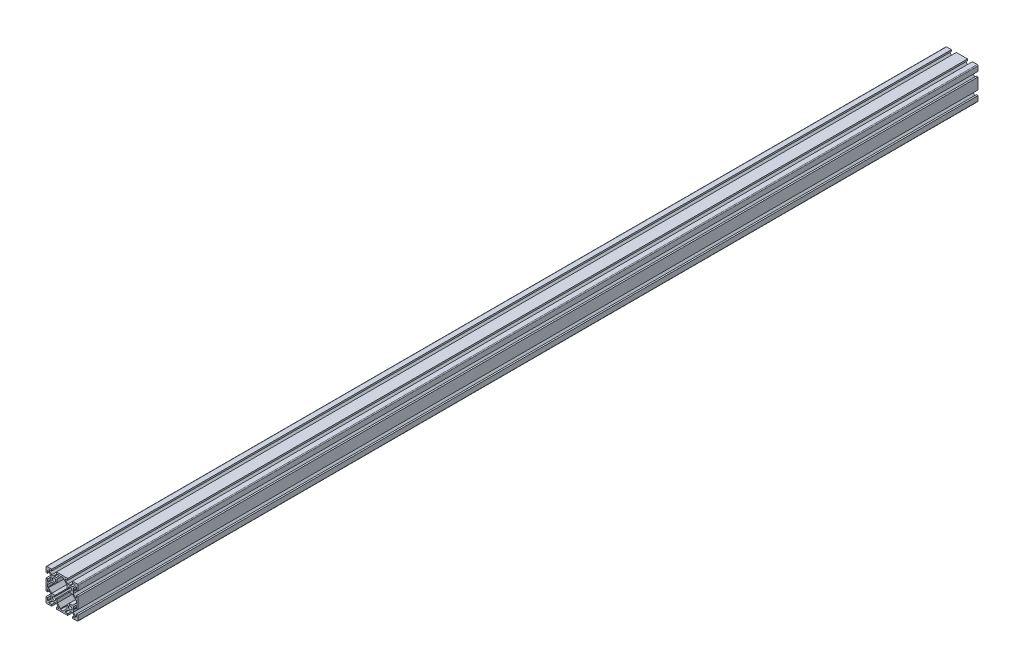
from build123d import *

# Parameters (mm, degrees)
BOSS_EXTRUDE1_DEPTH = 1120
CUT_EXTRUDE1_DEPTH  = 1182


with BuildPart() as part:
    # Sketch1 → Boss-Extrude1 (new body)
    with BuildSketch(Plane.XY):
        with BuildLine():
            Line((-20, 13), (-18, 13))
            Line((-18, 13), (-18, 16))
            Line((-18, 16), (-17.060660172, 16))
            Line((-17.060660172, 16), (-14, 12.939339828))
            Line((-14, 12.939339828), (-14, 10.519615242))
            Line((-14, 10.519615242), (-13.7, 10))
            Line((-13.7, 10), (-14, 9.480384758))
            Line((-14, 9.480384758), (-14, 7.060660172))
            Line((-14, 7.060660172), (-17.060660172, 4))
            Line((-17.060660172, 4), (-18, 4))
            Line((-18, 4), (-18, 7))
            Line((-18, 7), (-20, 7))
            Line((-20, 7), (-20, -7))
            Line((-20, -7), (-18, -7))
            Line((-18, -7), (-18, -4))
            Line((-18, -4), (-17.060660172, -4))
            Line((-17.060660172, -4), (-14, -7.060660172))
            Line((-14, -7.060660172), (-14, -9.480384758))
            Line((-14, -9.480384758), (-13.7, -10))
            Line((-13.7, -10), (-14, -10.519615242))
            Line((-14, -10.519615242), (-14, -12.939339828))
            Line((-14, -12.939339828), (-17.060660172, -16))
            Line((-17.060660172, -16), (-18, -16))
            Line((-18, -16), (-18, -13))
            Line((-18, -13), (-20, -13))
            Line((-20, -13), (-20, -19))
            ThreePointArc((-20, -19), (-19.707106781, -19.707106781), (-19, -20))
            Line((-19, -20), (-13, -20))
            Line((-13, -20), (-13, -18))
            Line((-13, -18), (-16, -18))
            Line((-16, -18), (-16, -17.060660172))
            Line((-16, -17.060660172), (-12.939339828, -14))
            Line((-12.939339828, -14), (-10.519615242, -14))
            Line((-10.519615242, -14), (-10, -13.7))
            Line((-10, -13.7), (-9.480384758, -14))
            Line((-9.480384758, -14), (-7.060660172, -14))
            Line((-7.060660172, -14), (-4, -17.060660172))
            Line((-4, -17.060660172), (-4, -18))
            Line((-4, -18), (-7, -18))
            Line((-7, -18), (-7, -20))
            Line((-7, -20), (7, -20))
            Line((7, -20), (7, -18))
            Line((7, -18), (4, -18))
            Line((4, -18), (4, -17.060660172))
            Line((4, -17.060660172), (7.060660172, -14))
            Line((7.060660172, -14), (9.480384758, -14))
            Line((9.480384758, -14), (10, -13.7))
            Line((10, -13.7), (10.519615242, -14))
            Line((10.519615242, -14), (12.939339828, -14))
            Line((12.939339828, -14), (16, -17.060660172))
            Line((16, -17.060660172), (16, -18))
            Line((16, -18), (13, -18))
            Line((13, -18), (13, -20))
            Line((13, -20), (19, -20))
            ThreePointArc((19, -20), (19.707106781, -19.707106781), (20, -19))
            Line((20, -19), (20, -13))
            Line((20, -13), (18, -13))
            Line((18, -13), (18, -16))
            Line((18, -16), (17.060660172, -16))
            Line((17.060660172, -16), (14, -12.939339828))
            Line((14, -12.939339828), (14, -10.519615242))
            Line((14, -10.519615242), (13.7, -10))
            Line((13.7, -10), (14, -9.480384758))
            Line((14, -9.480384758), (14, -7.060660172))
            Line((14, -7.060660172), (17.060660172, -4))
            Line((17.060660172, -4), (18, -4))
            Line((18, -4), (18, -7))
            Line((18, -7), (20, -7))
            Line((20, -7), (20, 7))
            Line((20, 7), (18, 7))
            Line((18, 7), (18, 4))
            Line((18, 4), (17.060660172, 4))
            Line((17.060660172, 4), (14, 7.060660172))
            Line((14, 7.060660172), (14, 9.480384758))
            Line((14, 9.480384758), (13.7, 10))
            Line((13.7, 10), (14, 10.519615242))
            Line((14, 10.519615242), (14, 12.939339828))
            Line((14, 12.939339828), (17.060660172, 16))
            Line((17.060660172, 16), (18, 16))
            Line((18, 16), (18, 13))
            Line((18, 13), (20, 13))
            Line((20, 13), (20, 19))
            ThreePointArc((20, 19), (19.707106781, 19.707106781), (19, 20))
            Line((19, 20), (13, 20))
            Line((13, 20), (13, 18))
            Line((13, 18), (16, 18))
            Line((16, 18), (16, 17.060660172))
            Line((16, 17.060660172), (12.939339828, 14))
            Line((12.939339828, 14), (10.519615242, 14))
            Line((10.519615242, 14), (10, 13.7))
            Line((10, 13.7), (9.480384758, 14))
            Line((9.480384758, 14), (7.060660172, 14))
            Line((7.060660172, 14), (4, 17.060660172))
            Line((4, 17.060660172), (4, 18))
            Line((4, 18), (7, 18))
            Line((7, 18), (7, 20))
            Line((7, 20), (-7, 20))
            Line((-7, 20), (-7, 18))
            Line((-7, 18), (-4, 18))
            Line((-4, 18), (-4, 17.060660172))
            Line((-4, 17.060660172), (-7.060660172, 14))
            Line((-7.060660172, 14), (-9.480384758, 14))
            Line((-9.480384758, 14), (-10, 13.7))
            Line((-10, 13.7), (-10.519615242, 14))
            Line((-10.519615242, 14), (-12.939339828, 14))
            Line((-12.939339828, 14), (-16, 17.060660172))
            Line((-16, 17.060660172), (-16, 18))
            Line((-16, 18), (-13, 18))
            Line((-13, 18), (-13, 20))
            Line((-13, 20), (-19, 20))
            ThreePointArc((-19, 20), (-19.707106781, 19.707106781), (-20, 19))
            Line((-20, 19), (-20, 13))
        make_face()
    extrude(amount=-BOSS_EXTRUDE1_DEPTH)

    # Sketch2 → Cut-Extrude1 (cut)
    with BuildSketch(Plane.XY):
        with BuildLine():
            Line((-18, 2), (-18, -2))
            Line((-18, -2), (-16.939339828, -2))
            Line((-16.939339828, -2), (-12.939339828, -6))
            Line((-12.939339828, -6), (-8.666662697, -6))
            Line((-8.666662697, -6), (-9.335919912, -8.007765667))
            ThreePointArc((-9.335919912, -8.007765667), (-11.48492424, -11.48492424), (-8.007765667, -9.335919912))
            Line((-8.007765667, -9.335919912), (-6, -8.666662697))
            Line((-6, -8.666662697), (-6, -12.939339828))
            Line((-6, -12.939339828), (-2, -16.939339828))
            Line((-2, -16.939339828), (-2, -18))
            Line((-2, -18), (2, -18))
            Line((2, -18), (2, -16.939339828))
            Line((2, -16.939339828), (6, -12.939339828))
            Line((6, -12.939339828), (6, -8.666662697))
            Line((6, -8.666662697), (8.007765667, -9.335919912))
            ThreePointArc((8.007765667, -9.335919912), (11.48492424, -11.48492424), (9.335919912, -8.007765667))
            Line((9.335919912, -8.007765667), (8.666662697, -6))
            Line((8.666662697, -6), (12.939339828, -6))
            Line((12.939339828, -6), (16.939339828, -2))
            Line((16.939339828, -2), (18, -2))
            Line((18, -2), (18, 2))
            Line((18, 2), (16.939339828, 2))
            Line((16.939339828, 2), (12.939339828, 6))
            Line((12.939339828, 6), (8.666662697, 6))
            Line((8.666662697, 6), (9.335919912, 8.007765667))
            ThreePointArc((9.335919912, 8.007765667), (11.48492424, 11.48492424), (8.007765667, 9.335919912))
            Line((8.007765667, 9.335919912), (6, 8.666662697))
            Line((6, 8.666662697), (6, 12.939339828))
            Line((6, 12.939339828), (2, 16.939339828))
            Line((2, 16.939339828), (2, 18))
            Line((2, 18), (-2, 18))
            Line((-2, 18), (-2, 16.939339828))
            Line((-2, 16.939339828), (-6, 12.939339828))
            Line((-6, 12.939339828), (-6, 8.666662697))
            Line((-6, 8.666662697), (-8.007765667, 9.335919912))
            ThreePointArc((-8.007765667, 9.335919912), (-11.48492424, 11.48492424), (-9.335919912, 8.007765667))
            Line((-9.335919912, 8.007765667), (-8.666662697, 6))
            Line((-8.666662697, 6), (-12.939339828, 6))
            Line((-12.939339828, 6), (-16.939339828, 2))
            Line((-16.939339828, 2), (-18, 2))
        make_face()
    extrude(amount=-CUT_EXTRUDE1_DEPTH, mode=Mode.SUBTRACT)


solid = part.part
